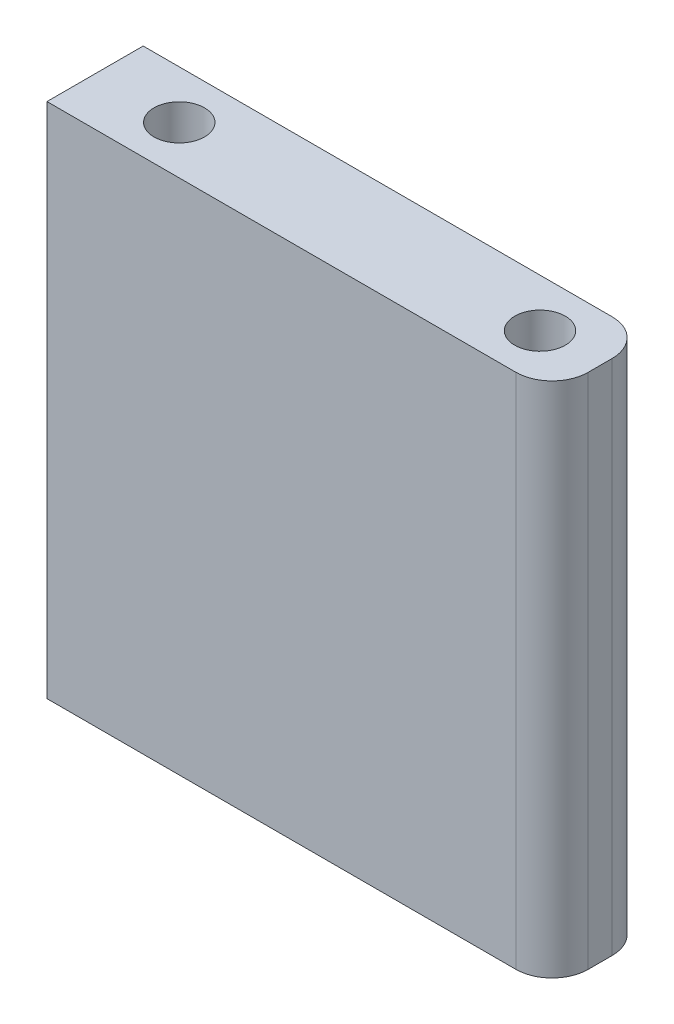
from build123d import *

# Parameters (mm, degrees)
SKETCH1_W           = 42
SKETCH1_H           = 43
BOSS_EXTRUDE1_DEPTH = 8
SKETCH2_R           = 2.1
CUT_EXTRUDE1_DEPTH  = 10
SKETCH3_R           = 2.1
CUT_EXTRUDE2_DEPTH  = 10
FILLET1_R           = 3


with BuildPart() as part:
    # Sketch1 → Boss-Extrude1 (new body)
    with BuildSketch(Plane.XY):
        with Locations((21, 21.5)):
            Rectangle(SKETCH1_W, SKETCH1_H)
    extrude(amount=BOSS_EXTRUDE1_DEPTH)

    # Sketch2 → Cut-Extrude1 (cut)
    with BuildSketch(Plane.XZ):
        with Locations((37, 4)):
            Circle(SKETCH2_R)
        with Locations((7, 4)):
            Circle(SKETCH2_R)
    extrude(amount=-CUT_EXTRUDE1_DEPTH, mode=Mode.SUBTRACT)

    # Sketch3 → Cut-Extrude2 (cut)
    with BuildSketch(Plane(origin=(0, 43, 0), x_dir=(1, 0, 0), z_dir=(0, 1, 0))):
        with Locations((37, -4)):
            Circle(SKETCH3_R)
        with Locations((7, -4)):
            Circle(SKETCH3_R)
    extrude(amount=-CUT_EXTRUDE2_DEPTH, mode=Mode.SUBTRACT)

    # Fillet1
    fillet1_edges = [part.edges().sort_by_distance(p)[0] for p in [
        (42, 21.5, 8),
        (42, 21.5, 0),
    ]]
    fillet(fillet1_edges, radius=FILLET1_R)


solid = part.part
